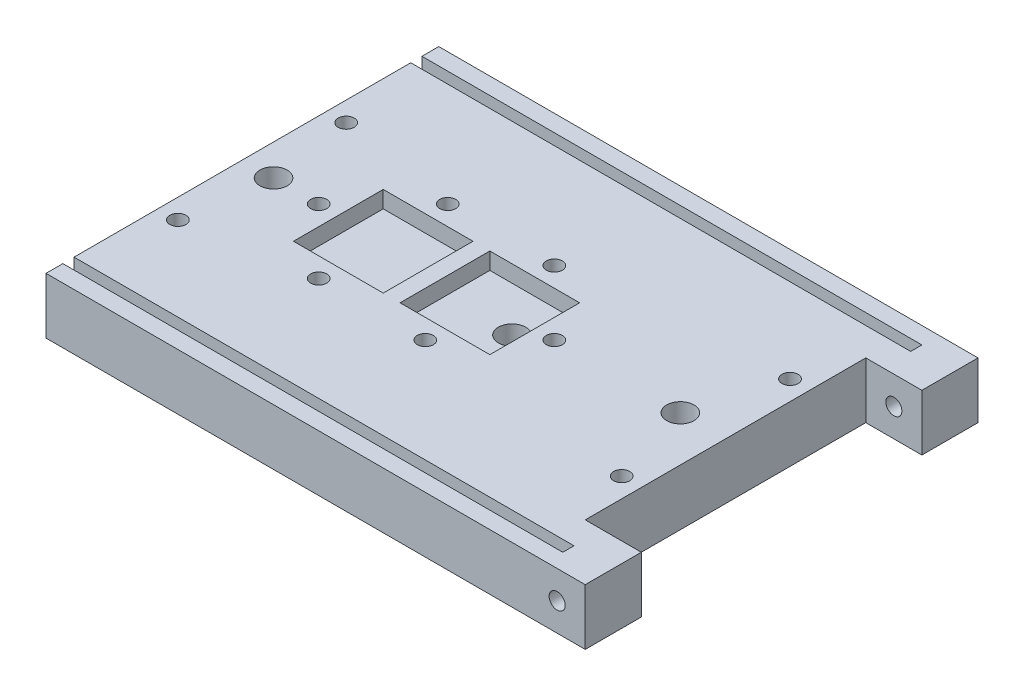
from build123d import *

# Parameters (mm, degrees)
SALIENTE_EXTRUIR1_DEPTH = 10
CROQUIS7_W              = 86.1
CROQUIS7_H              = 2
CORTAR_EXTRUIR4_DEPTH   = 3
CROQUIS15_R             = 1.435
CORTAR_EXTRUIR10_DEPTH  = 10
CROQUIS16_W             = 10
CROQUIS16_H             = 10
SALIENTE_EXTRUIR7_DEPTH = 10
CROQUIS17_W             = 3
CROQUIS17_H             = 2
CORTAR_EXTRUIR11_DEPTH  = 3
CROQUIS18_R             = 1.435
CORTAR_EXTRUIR12_DEPTH  = 10
CROQUIS19_R             = 1.435
CORTAR_EXTRUIR13_DEPTH  = 10
CROQUIS20_R             = 1.435
CORTAR_EXTRUIR14_DEPTH  = 10
CROQUIS21_R             = 2.435
CORTAR_EXTRUIR15_DEPTH  = 10
CROQUIS2_W              = 16
CROQUIS2_H              = 16
CORTAR_EXTRUIR16_DEPTH  = 3
CROQUIS22_R             = 1.435
CORTAR_EXTRUIR17_DEPTH  = 10


with BuildPart() as part:
    # Croquis1 → Saliente-Extruir1 (new body)
    with BuildSketch(Plane(origin=(0, 0, 0), x_dir=(1, 0, 0), z_dir=(0, 1, 0))):
        Polygon((22.5, -35), (51.5, -35), (51.5, 35), (22.5, 35), (-22.5, 35), (-34.6, 35), (-34.6, -35), (-22.5, -35), align=None)
    extrude(amount=SALIENTE_EXTRUIR1_DEPTH)

    # Croquis7 → Cortar-Extruir4 (cut)
    with BuildSketch(Plane(origin=(0, 10, 0), x_dir=(1, 0, 0), z_dir=(0, 1, 0))):
        with Locations((8.45, 31)):
            Rectangle(CROQUIS7_W, CROQUIS7_H)
    cortar_extruir4 = extrude(amount=-CORTAR_EXTRUIR4_DEPTH, mode=Mode.SUBTRACT)

    # Simetría2: Cortar-Extruir4 across plane
    add(cortar_extruir4.mirror(Plane.XY), mode=Mode.SUBTRACT)

    # Croquis15 → Cortar-Extruir10 (cut)
    with BuildSketch(Plane(origin=(0, 10, 0), x_dir=(1, 0, 0), z_dir=(0, 1, 0))):
        with Locations((-31.1, -15)):
            Circle(CROQUIS15_R)
    cortar_extruir10 = extrude(amount=-CORTAR_EXTRUIR10_DEPTH, mode=Mode.SUBTRACT)

    # Simetría4: Cortar-Extruir10 across plane
    add(cortar_extruir10.mirror(Plane.XY), mode=Mode.SUBTRACT)

    # Croquis16 → Saliente-Extruir7 (add)
    with BuildSketch(Plane(origin=(51.5, 0, 0), x_dir=(0, 0, -1), z_dir=(1, 0, 0))):
        with Locations((-30, 5)):
            Rectangle(CROQUIS16_W, CROQUIS16_H)
    saliente_extruir7 = extrude(amount=SALIENTE_EXTRUIR7_DEPTH)

    # Croquis17 → Cortar-Extruir11 (cut)
    with BuildSketch(Plane(origin=(0, 10, 0), x_dir=(1, 0, 0), z_dir=(0, 1, 0))):
        with Locations((53, -31)):
            Rectangle(CROQUIS17_W, CROQUIS17_H)
    cortar_extruir11 = extrude(amount=-CORTAR_EXTRUIR11_DEPTH, mode=Mode.SUBTRACT)

    # Simetría5: Saliente-Extruir7, Cortar-Extruir11 across plane
    add(saliente_extruir7.mirror(Plane.XY))
    add(cortar_extruir11.mirror(Plane.XY), mode=Mode.SUBTRACT)

    # Croquis18 → Cortar-Extruir12 (cut)
    with BuildSketch(Plane(origin=(0, 10, 0), x_dir=(1, 0, 0), z_dir=(0, 1, 0))):
        with Locations((48, 15)):
            Circle(CROQUIS18_R)
    cortar_extruir12 = extrude(amount=-CORTAR_EXTRUIR12_DEPTH, mode=Mode.SUBTRACT)

    # Simetría6: Cortar-Extruir12 across plane
    add(cortar_extruir12.mirror(Plane.XY), mode=Mode.SUBTRACT)

    # Croquis19 → Cortar-Extruir13 (cut)
    with BuildSketch(Plane.ZY.offset(34.6)):
        with Locations((26.5, 5)):
            Circle(CROQUIS19_R)
    cortar_extruir13 = extrude(amount=-CORTAR_EXTRUIR13_DEPTH, mode=Mode.SUBTRACT)

    # Simetría7: Cortar-Extruir13 across plane
    add(cortar_extruir13.mirror(Plane.XY), mode=Mode.SUBTRACT)

    # Croquis20 → Cortar-Extruir14 (cut)
    with BuildSketch(Plane.XY.offset(35)):
        with Locations((56.5, 5)):
            Circle(CROQUIS20_R)
    cortar_extruir14 = extrude(amount=-CORTAR_EXTRUIR14_DEPTH, mode=Mode.SUBTRACT)

    # Simetría8: Cortar-Extruir14 across plane
    add(cortar_extruir14.mirror(Plane.XY), mode=Mode.SUBTRACT)

    # Croquis21 → Cortar-Extruir15 (cut)
    with BuildSketch(Plane.XZ):
        with Locations((13.45, 0)):
            Circle(CROQUIS21_R)
        with Locations((43.45, 0)):
            Circle(CROQUIS21_R)
        with Locations((-29.05, 0)):
            Circle(CROQUIS21_R)
    extrude(amount=-CORTAR_EXTRUIR15_DEPTH, mode=Mode.SUBTRACT)

    # Croquis2 → Cortar-Extruir16 (cut)
    with BuildSketch(Plane(origin=(0, 10, 0), x_dir=(1, 0, 0), z_dir=(0, 1, 0))):
        with Locations((9.5, 0)):
            Rectangle(CROQUIS2_W, CROQUIS2_H)
    cortar_extruir16 = extrude(amount=-CORTAR_EXTRUIR16_DEPTH, mode=Mode.SUBTRACT)

    # Simetría9: Cortar-Extruir16 across plane
    add(cortar_extruir16.mirror(Plane(origin=(0, 0, 0), x_dir=(0, 0, 1), z_dir=(1, 0, 0))), mode=Mode.SUBTRACT)

    # Croquis22 → Cortar-Extruir17 (cut)
    with BuildSketch(Plane(origin=(0, 10, 0), x_dir=(1, 0, 0), z_dir=(0, 1, 0))):
        with Locations((-9.5, 11.5)):
            Circle(CROQUIS22_R)
        with Locations((-21, 0)):
            Circle(CROQUIS22_R)
        with Locations((-9.5, -11.5)):
            Circle(CROQUIS22_R)
    cortar_extruir17 = extrude(amount=-CORTAR_EXTRUIR17_DEPTH, mode=Mode.SUBTRACT)

    # Simetría10: Cortar-Extruir17 across plane
    add(cortar_extruir17.mirror(Plane(origin=(0, 0, 0), x_dir=(0, 0, 1), z_dir=(1, 0, 0))), mode=Mode.SUBTRACT)


solid = part.part
